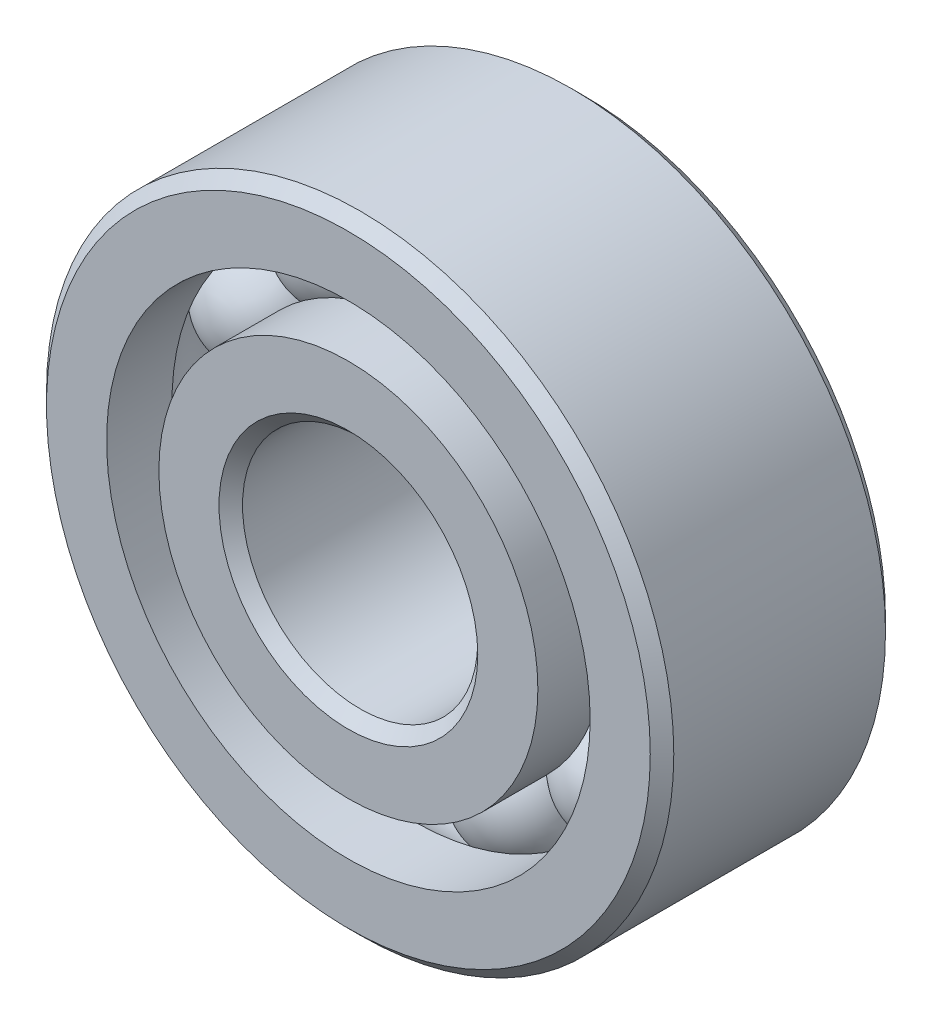
from build123d import *

# Parameters (mm, degrees)
CIRPATTERN1_COUNT = 11


with BuildPart() as part:
    # Sketch2 → Revolve1 (revolve)
    with BuildSketch(Plane(origin=(0, 0, 0), x_dir=(0, 0, -1), z_dir=(1, 0, 0))):
        with BuildLine():
            Line((-1.5, 2.416666667), (-0.666666667, 2.416666667))
            ThreePointArc((-0.666666667, 2.416666667), (0, 2.004644008), (0.666666667, 2.416666667))
            Line((0.666666667, 2.416666667), (1.5, 2.416666667))
            Line((1.5, 2.416666667), (1.5, 1.65))
            Line((1.5, 1.65), (1.35, 1.5))
            Line((1.35, 1.5), (-1.35, 1.5))
            Line((-1.35, 1.5), (-1.5, 1.65))
            Line((-1.5, 1.65), (-1.5, 2.416666667))
        make_face()
        with BuildLine():
            Line((1.35, 4), (1.5, 3.85))
            Line((1.5, 3.85), (1.5, 3.083333333))
            Line((1.5, 3.083333333), (0.666666667, 3.083333333))
            ThreePointArc((0.666666667, 3.083333333), (0, 3.495355992), (-0.666666667, 3.083333333))
            Line((-0.666666667, 3.083333333), (-1.5, 3.083333333))
            Line((-1.5, 3.083333333), (-1.5, 3.85))
            Line((-1.5, 3.85), (-1.35, 4))
            Line((-1.35, 4), (1.35, 4))
        make_face()
    revolve(axis=Axis((0, 0, 1.5), (0, 0, -1)))


with BuildPart() as body_2:
    # Sketch3 → Revolve2 (revolve)
    with BuildSketch(Plane(origin=(0, 0, 0), x_dir=(0, 0, -1), z_dir=(1, 0, 0))):
        with BuildLine():
            Line((-0.745355992, 2.75), (0.745355992, 2.75))
            ThreePointArc((0.745355992, 2.75), (0, 3.495355992), (-0.745355992, 2.75))
        make_face()
    revolve(axis=Axis((0, 2.75, 0.745355992), (0, 0, -1)))


with BuildPart() as cirpattern1_1:
    # CirPattern1: pattern copy
    add(body_2.part.rotate(Axis((0, 0, -1.5), (0, 0, 1)), 1 * 360 / CIRPATTERN1_COUNT))


with BuildPart() as cirpattern1_2:
    # CirPattern1: pattern copy
    add(body_2.part.rotate(Axis((0, 0, -1.5), (0, 0, 1)), 2 * 360 / CIRPATTERN1_COUNT))


with BuildPart() as cirpattern1_3:
    # CirPattern1: pattern copy
    add(body_2.part.rotate(Axis((0, 0, -1.5), (0, 0, 1)), 3 * 360 / CIRPATTERN1_COUNT))


with BuildPart() as cirpattern1_4:
    # CirPattern1: pattern copy
    add(body_2.part.rotate(Axis((0, 0, -1.5), (0, 0, 1)), 4 * 360 / CIRPATTERN1_COUNT))


with BuildPart() as cirpattern1_5:
    # CirPattern1: pattern copy
    add(body_2.part.rotate(Axis((0, 0, -1.5), (0, 0, 1)), 5 * 360 / CIRPATTERN1_COUNT))


with BuildPart() as cirpattern1_6:
    # CirPattern1: pattern copy
    add(body_2.part.rotate(Axis((0, 0, -1.5), (0, 0, 1)), 6 * 360 / CIRPATTERN1_COUNT))


with BuildPart() as cirpattern1_7:
    # CirPattern1: pattern copy
    add(body_2.part.rotate(Axis((0, 0, -1.5), (0, 0, 1)), 7 * 360 / CIRPATTERN1_COUNT))


with BuildPart() as cirpattern1_8:
    # CirPattern1: pattern copy
    add(body_2.part.rotate(Axis((0, 0, -1.5), (0, 0, 1)), 8 * 360 / CIRPATTERN1_COUNT))


with BuildPart() as cirpattern1_9:
    # CirPattern1: pattern copy
    add(body_2.part.rotate(Axis((0, 0, -1.5), (0, 0, 1)), 9 * 360 / CIRPATTERN1_COUNT))


with BuildPart() as cirpattern1_10:
    # CirPattern1: pattern copy
    add(body_2.part.rotate(Axis((0, 0, -1.5), (0, 0, 1)), 10 * 360 / CIRPATTERN1_COUNT))


solid = Compound([part.part, body_2.part, cirpattern1_1.part, cirpattern1_2.part, cirpattern1_3.part, cirpattern1_4.part, cirpattern1_5.part, cirpattern1_6.part, cirpattern1_7.part, cirpattern1_8.part, cirpattern1_9.part, cirpattern1_10.part])
